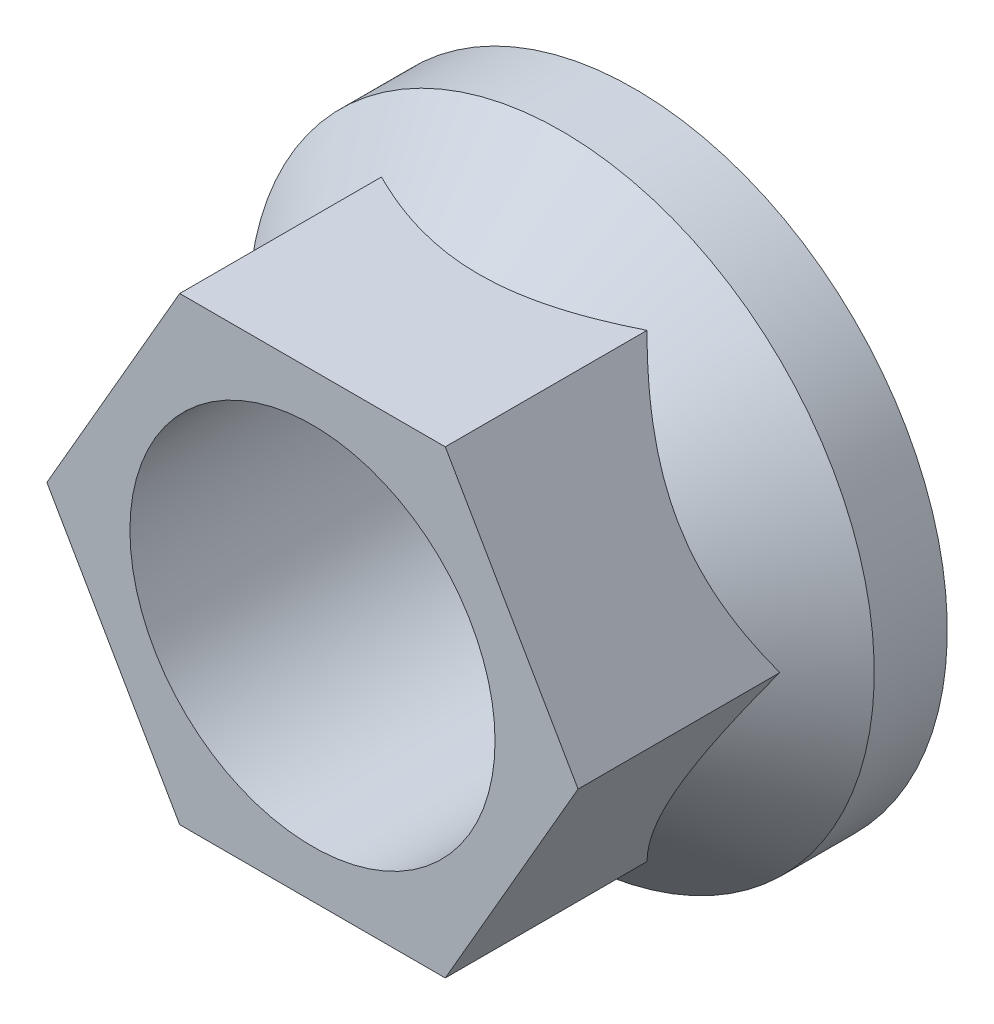
from build123d import *

# Parameters (mm, degrees)
BOSS_EXTRUDE1_REACH = 9
SKETCH2_R           = 3.96875


with BuildPart() as part:
    # Sketch1 → Revolve1 (revolve)
    with BuildSketch(Plane(origin=(0, 0, 0), x_dir=(0, 0, -1), z_dir=(1, 0, 0))):
        Polygon((0, 3.96875), (-7, 3.96875), (-7, 4.7625), (-3.625, 4.7625), (-1.5875, 6.8), (0, 6.8), align=None)
    revolve(axis=Axis((0, 0, 0), (0, 0, 1)))

    # Sketch2 → Boss-Extrude1 (add, up to next)
    with BuildSketch(Plane.XY.offset(7), mode=Mode.PRIVATE) as boss_extrude1_sk1:
        Polygon((-2.886751346, 5), (-5.773502692, 0), (-2.886751346, -5), (2.886751346, -5), (5.773502692, 0), (2.886751346, 5), align=None)
        Circle(SKETCH2_R, mode=Mode.SUBTRACT)
    boss_extrude1_tool1 = extrude(boss_extrude1_sk1.sketch, amount=-BOSS_EXTRUDE1_REACH, mode=Mode.PRIVATE) - part.part
    add(boss_extrude1_tool1.solids().sort_by_distance((-4.197839, 2.423624, 7))[0])


solid = part.part
